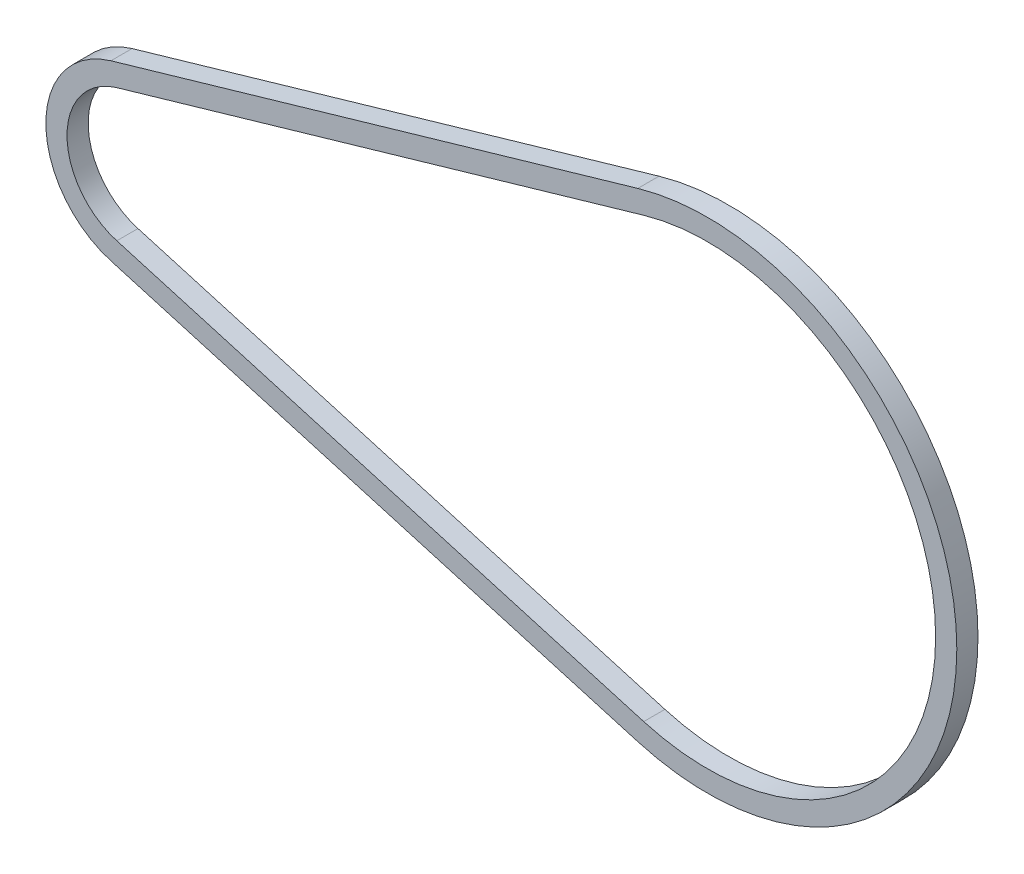
from build123d import *

# Parameters (mm, degrees)
EXTRUDE_THIN1_DEPTH = 1.27


with BuildPart() as part:
    # Sketch1 → Extrude-Thin1 (new body, symmetric)
    with BuildSketch(Plane.XY):
        with BuildLine():
            Line((60.177498144, -28.732118421), (-3.015801488, -10.390482501))
            ThreePointArc((-3.015801488, -10.390482501), (-10.819296891, 0), (-3.015801488, 10.390482501))
            Line((-3.015801488, 10.390482501), (60.177498144, 28.732118421))
            ThreePointArc((60.177498144, 28.732118421), (98.434786481, 0), (60.177498144, -28.732118421))
        make_face()
        with BuildLine():
            Line((60.885504945, -26.292789339), (-2.307794687, -7.951153419))
            ThreePointArc((-2.307794687, -7.951153419), (-8.279296891, 0), (-2.307794687, 7.951153419))
            Line((-2.307794687, 7.951153419), (60.885504945, 26.292789339))
            ThreePointArc((60.885504945, 26.292789339), (95.894786481, 0), (60.885504945, -26.292789339))
        make_face(mode=Mode.SUBTRACT)
    extrude(amount=EXTRUDE_THIN1_DEPTH, both=True)


solid = part.part
